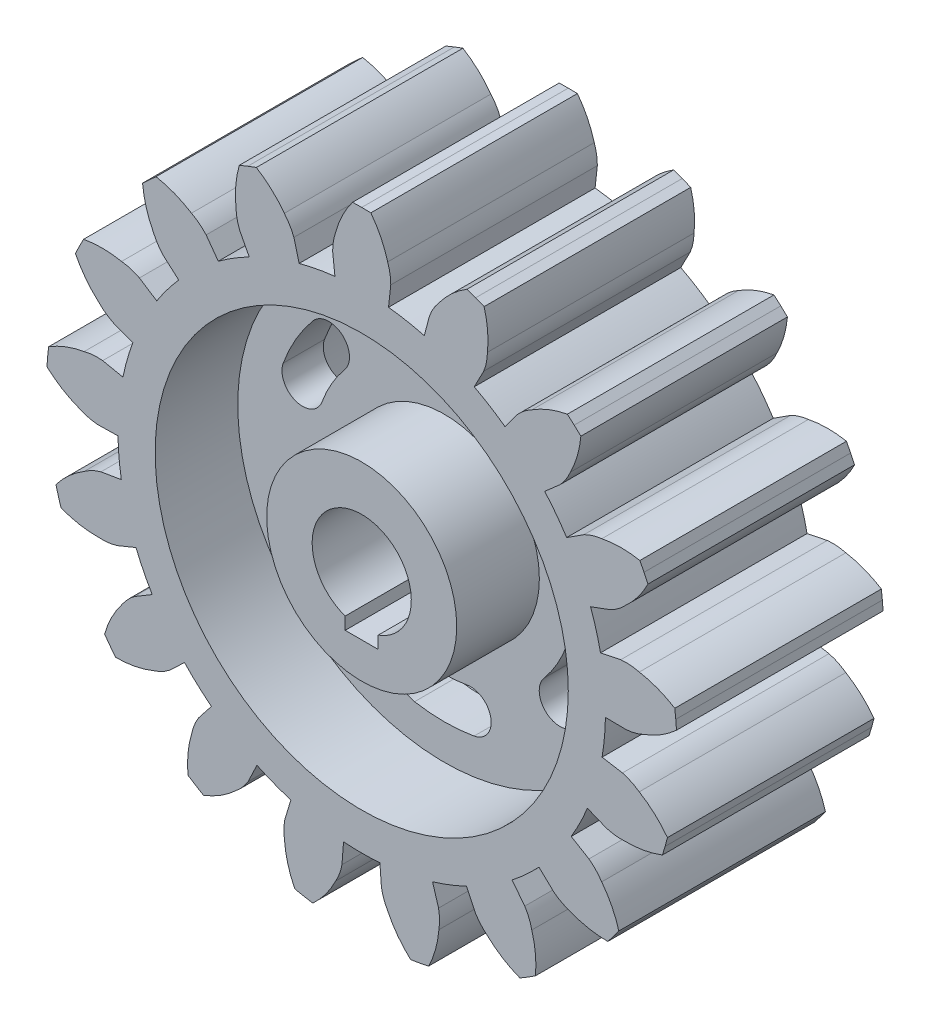
from build123d import *

# Parameters (mm, degrees)
ESBO_O1_R                  = 59
ESBO_O1_R_2                = 50
RESSALTO_EXTRUS_O2_DEPTH   = 25
ESBO_O1_R_3                = 23
RESSALTO_EXTRUS_O2_2_DEPTH = 25
ESBO_O1_6_R                = 50
ESBO_O1_6_R_2              = 23
RESSALTO_EXTRUS_O3_DEPTH   = 5
RESSALTO_EXTRUS_O4_DEPTH   = 25
PADR_OCIRCULAR1_COUNT      = 17


with BuildPart() as part:
    # Esboço1 → Ressalto-extrusão2 (new, symmetric)
    with BuildSketch(Plane.XY):
        Circle(ESBO_O1_R)
        Circle(ESBO_O1_R_2, mode=Mode.SUBTRACT)
    extrude(amount=RESSALTO_EXTRUS_O2_DEPTH, both=True)



with BuildPart() as body_2:
    # Esboço1 → Ressalto-extrus_o2 2 (new, symmetric)
    with BuildSketch(Plane.XY):
        Circle(ESBO_O1_R_3)
        with BuildLine():
            ThreePointArc((-4, -11.313708499), (0, 12), (4, -11.313708499))
            Line((4, -11.313708499), (4, -14.313708499))
            Line((4, -14.313708499), (-4, -14.313708499))
            Line((-4, -14.313708499), (-4, -11.313708499))
        make_face(mode=Mode.SUBTRACT)
    extrude(amount=RESSALTO_EXTRUS_O2_2_DEPTH, both=True)


with BuildPart() as part_1:
    add(part.part)

    add(body_2.part)  # Ressalto-extrusão3 merges body 2
    # Esboço1<6> → Ressalto-extrusão3 (add, symmetric)
    with BuildSketch(Plane.XY):
        Circle(ESBO_O1_6_R)
        with BuildLine():
            ThreePointArc((-7.206399373, -40.86952175), (-11.26219725, -35.077242097), (-5.469917597, -31.02144422))
            ThreePointArc((-5.469917597, -31.02144422), (0, -31.5), (5.469917597, -31.02144422))
            ThreePointArc((5.469917597, -31.02144422), (11.26219725, -35.077242097), (7.206399373, -40.86952175))
            ThreePointArc((7.206399373, -40.86952175), (0, -41.5), (-7.206399373, -40.86952175))
        make_face(mode=Mode.SUBTRACT)
        with BuildLine():
            ThreePointArc((-38.997243763, -14.193835948), (-36.008881375, -7.785272127), (-29.600317555, -10.773634515))
            ThreePointArc((-29.600317555, -10.773634515), (-27.279800219, -15.75), (-24.130399958, -20.247809705))
            ThreePointArc((-24.130399958, -20.247809705), (-24.746684125, -27.291969969), (-31.790844389, -26.675685802))
            ThreePointArc((-31.790844389, -26.675685802), (-35.940054257, -20.75), (-38.997243763, -14.193835948))
        make_face(mode=Mode.SUBTRACT)
        Circle(ESBO_O1_6_R_2, mode=Mode.SUBTRACT)
        with BuildLine():
            ThreePointArc((31.790844389, -26.675685802), (24.746684125, -27.291969969), (24.130399958, -20.247809705))
            ThreePointArc((24.130399958, -20.247809705), (27.279800219, -15.75), (29.600317555, -10.773634515))
            ThreePointArc((29.600317555, -10.773634515), (36.008881375, -7.785272127), (38.997243763, -14.193835948))
            ThreePointArc((38.997243763, -14.193835948), (35.940054257, -20.75), (31.790844389, -26.675685802))
        make_face(mode=Mode.SUBTRACT)
        with BuildLine():
            ThreePointArc((-31.790844389, 26.675685802), (-24.746684125, 27.291969969), (-24.130399958, 20.247809705))
            ThreePointArc((-24.130399958, 20.247809705), (-27.279800219, 15.75), (-29.600317555, 10.773634515))
            ThreePointArc((-29.600317555, 10.773634515), (-36.008881375, 7.785272127), (-38.997243763, 14.193835948))
            ThreePointArc((-38.997243763, 14.193835948), (-35.940054257, 20.75), (-31.790844389, 26.675685802))
        make_face(mode=Mode.SUBTRACT)
        with BuildLine():
            ThreePointArc((-7.206399373, 40.86952175), (0, 41.5), (7.206399373, 40.86952175))
            ThreePointArc((7.206399373, 40.86952175), (11.26219725, 35.077242097), (5.469917597, 31.02144422))
            ThreePointArc((5.469917597, 31.02144422), (0, 31.5), (-5.469917597, 31.02144422))
            ThreePointArc((-5.469917597, 31.02144422), (-11.26219725, 35.077242097), (-7.206399373, 40.86952175))
        make_face(mode=Mode.SUBTRACT)
        with BuildLine():
            ThreePointArc((38.997243763, 14.193835948), (36.008881375, 7.785272127), (29.600317555, 10.773634515))
            ThreePointArc((29.600317555, 10.773634515), (27.279800219, 15.75), (24.130399958, 20.247809705))
            ThreePointArc((24.130399958, 20.247809705), (24.746684125, 27.291969969), (31.790844389, 26.675685802))
            ThreePointArc((31.790844389, 26.675685802), (35.940054257, 20.75), (38.997243763, 14.193835948))
        make_face(mode=Mode.SUBTRACT)
    extrude(amount=RESSALTO_EXTRUS_O3_DEPTH, both=True)

    # Esboço1<7> → Ressalto-extrusão4 (add, symmetric)
    with BuildSketch(Plane.XY):
        with BuildLine():
            Line((-7.031995822, 63.612506905), (-6.482621149, 58.642779803))
            ThreePointArc((-6.482621149, 58.642779803), (0, 59), (6.482621149, 58.642779803))
            Line((6.482621149, 58.642779803), (7.031995822, 63.612506905))
            ThreePointArc((7.031995822, 63.612506905), (6.855172325, 65.865421337), (6.28, 68.050842757))
            ThreePointArc((6.28, 68.050842757), (4.641794404, 72.375083689), (2.209746702, 76.308011503))
            Line((2.209746702, 76.308011503), (0, 76.34))
            Line((0, 76.34), (-2.209746702, 76.308011503))
            ThreePointArc((-2.209746702, 76.308011503), (-4.641794404, 72.375083689), (-6.28, 68.050842757))
            ThreePointArc((-6.28, 68.050842757), (-6.855172325, 65.865421337), (-7.031995822, 63.612506905))
        make_face()
    ressalto_extrus_o4 = extrude(amount=RESSALTO_EXTRUS_O4_DEPTH, both=True)

    # PadrãoCircular1: Ressalto-extrusão4 ×17 about axis
    padr_ocircular1_axis = Axis((0, 0, 25), (0, 0, 1))
    for i in range(1, PADR_OCIRCULAR1_COUNT):
        add(ressalto_extrus_o4.rotate(padr_ocircular1_axis, i * 360 / PADR_OCIRCULAR1_COUNT))


solid = part_1.part
